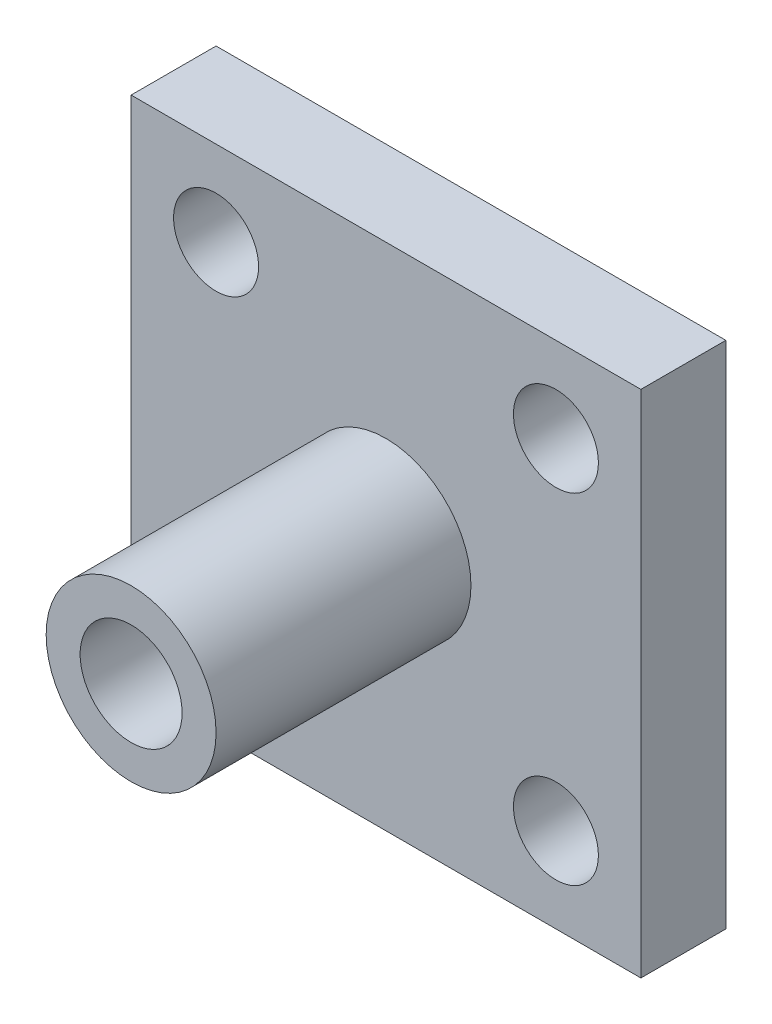
from build123d import *

# Parameters (mm, degrees)
ESBO_O1_W                = 30
ESBO_O1_H                = 30
ESBO_O1_R                = 2.5
RESSALTO_EXTRUS_O1_DEPTH = 5
ESBO_O3_R                = 5
RESSALTO_EXTRUS_O2_DEPTH = 15
ESBO_O4_R                = 3
CORTE_EXTRUS_O1_DEPTH    = 15
ESBO_O5_R                = 2
CORTE_EXTRUS_O2_DEPTH    = 15


with BuildPart() as part:
    # Esboço1 → Ressalto-extrusão1 (new body)
    with BuildSketch(Plane.XY):
        Rectangle(ESBO_O1_W, ESBO_O1_H)
        with Locations((-10, 10)):
            Circle(ESBO_O1_R, mode=Mode.SUBTRACT)
        with Locations((10, 10)):
            Circle(ESBO_O1_R, mode=Mode.SUBTRACT)
        with Locations((10, -10)):
            Circle(ESBO_O1_R, mode=Mode.SUBTRACT)
        with Locations((-10, -10)):
            Circle(ESBO_O1_R, mode=Mode.SUBTRACT)
    extrude(amount=RESSALTO_EXTRUS_O1_DEPTH)

    # Esboço3 → Ressalto-extrusão2 (add)
    with BuildSketch(Plane.XY.offset(5)):
        Circle(ESBO_O3_R)
    extrude(amount=RESSALTO_EXTRUS_O2_DEPTH)

    # Esboço4 → Corte-extrusão1 (cut)
    with BuildSketch(Plane.XY.offset(20)):
        Circle(ESBO_O4_R)
    extrude(amount=-CORTE_EXTRUS_O1_DEPTH, mode=Mode.SUBTRACT)

    # Esboço5 → Corte-extrusão2 (cut)
    with BuildSketch(Plane(origin=(0, 0, 0), x_dir=(0, 0, -1), z_dir=(1, 0, 0))):
        with Locations((-8, 0)):
            Circle(ESBO_O5_R)
        with Locations((-14, 0)):
            Circle(ESBO_O5_R)
    extrude(amount=-CORTE_EXTRUS_O2_DEPTH, mode=Mode.SUBTRACT)


solid = part.part
